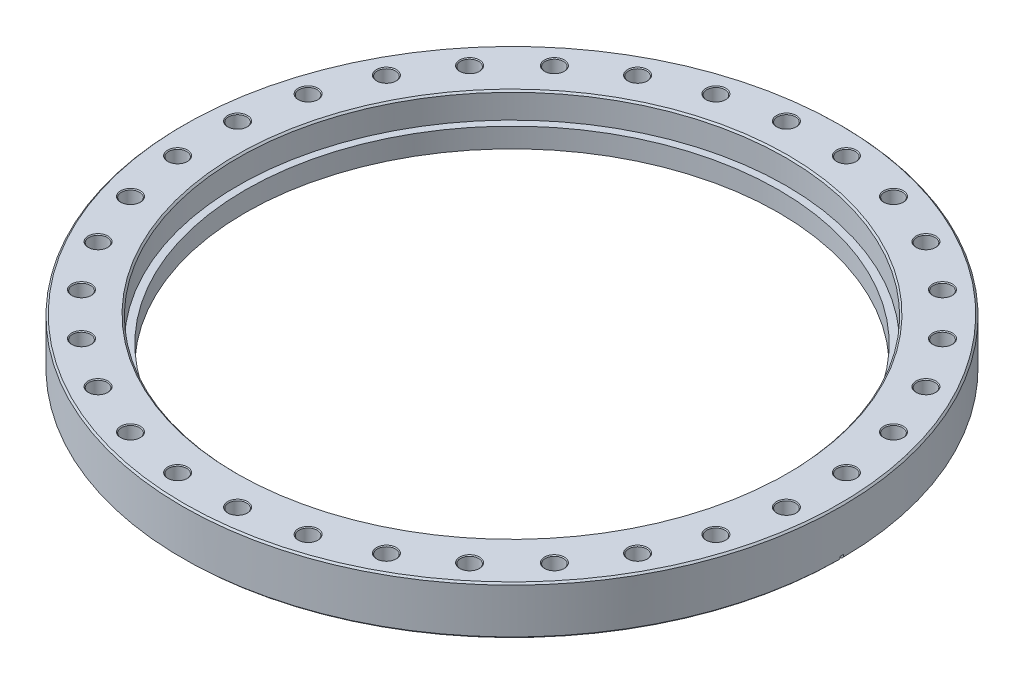
from build123d import *

# Parameters (mm, degrees)
SKETCH1_R                    = 152.9969
SKETCH1_R_2                  = 123.825
BOSS_EXTRUDE1_DEPTH          = 22.352
SKETCH2_R                    = 127.254
CUT_EXTRUDE1_DEPTH           = 11.938
CHAMFER1_SIZE                = 0.762
SKETCH3_R                    = 4.2164
CUT_EXTRUDE2_DEPTH           = 23.352
CHAMFER2_SIZE                = 0.381
CIRPATTERN1_COUNT            = 32
CHAMFER2_OF_CIRPATTERN1_SIZE = 0.381
CUT_EXTRUDE3_DEPTH           = 0.79375


with BuildPart() as part:
    # Sketch1 → Boss-Extrude1 (new body)
    with BuildSketch(Plane(origin=(0, 0, 0), x_dir=(1, 0, 0), z_dir=(0, 1, 0))):
        Circle(SKETCH1_R)
        Circle(SKETCH1_R_2, mode=Mode.SUBTRACT)
    extrude(amount=BOSS_EXTRUDE1_DEPTH)

    # Sketch2 → Cut-Extrude1 (cut)
    with BuildSketch(Plane(origin=(0, 22.352, 0), x_dir=(-1, 0, 0), z_dir=(0, -1, 0))):
        Circle(SKETCH2_R)
    extrude(amount=CUT_EXTRUDE1_DEPTH, mode=Mode.SUBTRACT)

    # Chamfer1
    chamfer1_edges = [part.edges().sort_by_distance(p)[0] for p in [
        (127.254, 22.352, 0),
        (-152.9969, 0, 0),
        (-152.9969, 22.352, 0),
    ]]
    chamfer(chamfer1_edges, length=CHAMFER1_SIZE)

    # Sketch4 → Cut-Revolve1 (revolve, cut)
    with BuildSketch(Plane.XY):
        Polygon((-137.16, 0), (-137.16, 1.6256), (-134.366, 0.6604), (-134.366, 1.27), (0, 1.27), (0, 0), align=None)
    revolve(axis=Axis((0, 22.352, 0), (0, -1, 0)), mode=Mode.SUBTRACT)

    # Sketch3 → Cut-Extrude2 (cut, through all)
    with BuildSketch(Plane(origin=(0, 22.352, 0), x_dir=(1, 0, 0), z_dir=(0, 1, 0))):
        with Locations((-13.918306505, 141.314937447)):
            Circle(SKETCH3_R)
    cut_extrude2 = extrude(amount=-CUT_EXTRUDE2_DEPTH, mode=Mode.SUBTRACT)

    # Chamfer2
    chamfer2_edges = [part.edges().sort_by_distance(p)[0] for p in [
        (-18.134706505, 0, -141.314937447),
        (-18.134706505, 22.352, -141.314937447),
    ]]
    chamfer(chamfer2_edges, length=CHAMFER2_SIZE)

    # CirPattern1: Cut-Extrude2 ×32 about axis
    cirpattern1_axis = Axis((0, 0, 0), (0, 1, 0))
    for i in range(1, CIRPATTERN1_COUNT):
        add(cut_extrude2.rotate(cirpattern1_axis, i * 360 / CIRPATTERN1_COUNT), mode=Mode.SUBTRACT)

    # Chamfer2 of CirPattern1
    chamfer2_of_cirpattern1_edges = [part.edges().sort_by_distance(p)[0] for p in [
        (-45.355429856, 0, -135.061704818),
        (-45.355429856, 22.352, -135.061704818),
        (-70.833169474, 0, -123.618126616),
        (-70.833169474, 22.352, -123.618126616),
        (-93.588830113, 0, -107.423973133),
        (-93.588830113, 22.352, -107.423973133),
        (-112.747924496, 0, -87.101576608),
        (-112.747924496, 22.352, -87.101576608),
        (-127.57417937, 0, -63.43191534),
        (-127.57417937, 22.352, -63.43191534),
        (-137.497830076, 0, -37.324601139),
        (-137.497830076, 22.352, -37.324601139),
        (-142.137516281, 0, -9.782923448),
        (-142.137516281, 22.352, -9.782923448),
        (-141.314937447, 0, 18.134706505),
        (-141.314937447, 22.352, 18.134706505),
        (-135.061704818, 0, 45.355429856),
        (-135.061704818, 22.352, 45.355429856),
        (-123.618126616, 0, 70.833169474),
        (-123.618126616, 22.352, 70.833169474),
        (-107.423973133, 0, 93.588830113),
        (-107.423973133, 22.352, 93.588830113),
        (-87.101576608, 0, 112.747924496),
        (-87.101576608, 22.352, 112.747924496),
        (-63.43191534, 0, 127.57417937),
        (-63.43191534, 22.352, 127.57417937),
        (-37.324601139, 0, 137.497830076),
        (-37.324601139, 22.352, 137.497830076),
        (-9.782923448, 0, 142.137516281),
        (-9.782923448, 22.352, 142.137516281),
        (18.134706505, 0, 141.314937447),
        (18.134706505, 22.352, 141.314937447),
        (45.355429856, 0, 135.061704818),
        (45.355429856, 22.352, 135.061704818),
        (70.833169474, 0, 123.618126616),
        (70.833169474, 22.352, 123.618126616),
        (93.588830113, 0, 107.423973133),
        (93.588830113, 22.352, 107.423973133),
        (112.747924496, 0, 87.101576608),
        (112.747924496, 22.352, 87.101576608),
        (127.57417937, 0, 63.43191534),
        (127.57417937, 22.352, 63.43191534),
        (137.497830076, 0, 37.324601139),
        (137.497830076, 22.352, 37.324601139),
        (142.137516281, 0, 9.782923448),
        (142.137516281, 22.352, 9.782923448),
        (141.314937447, 0, -18.134706505),
        (141.314937447, 22.352, -18.134706505),
        (135.061704818, 0, -45.355429856),
        (135.061704818, 22.352, -45.355429856),
        (123.618126616, 0, -70.833169474),
        (123.618126616, 22.352, -70.833169474),
        (107.423973133, 0, -93.588830113),
        (107.423973133, 22.352, -93.588830113),
        (87.101576608, 0, -112.747924496),
        (87.101576608, 22.352, -112.747924496),
        (63.43191534, 0, -127.57417937),
        (63.43191534, 22.352, -127.57417937),
        (37.324601139, 0, -137.497830076),
        (37.324601139, 22.352, -137.497830076),
        (9.782923448, 0, -142.137516281),
        (9.782923448, 22.352, -142.137516281),
    ]]
    chamfer(chamfer2_of_cirpattern1_edges, length=CHAMFER2_OF_CIRPATTERN1_SIZE)

    # Sketch5 → Cut-Extrude3 (cut, symmetric)
    with BuildSketch(Plane.XY):
        Polygon((-135.676131126, 0.888656944), (-152.9969, 1.796399976), (-152.9969, -6.22182779), (-135.676131126, -6.22182779), align=None)
        Polygon((135.676131126, 0.888656944), (135.676131126, -6.22182779), (152.9969, -6.22182779), (152.9969, 1.796399976), align=None)
    extrude(amount=CUT_EXTRUDE3_DEPTH, both=True, mode=Mode.SUBTRACT)


solid = part.part
